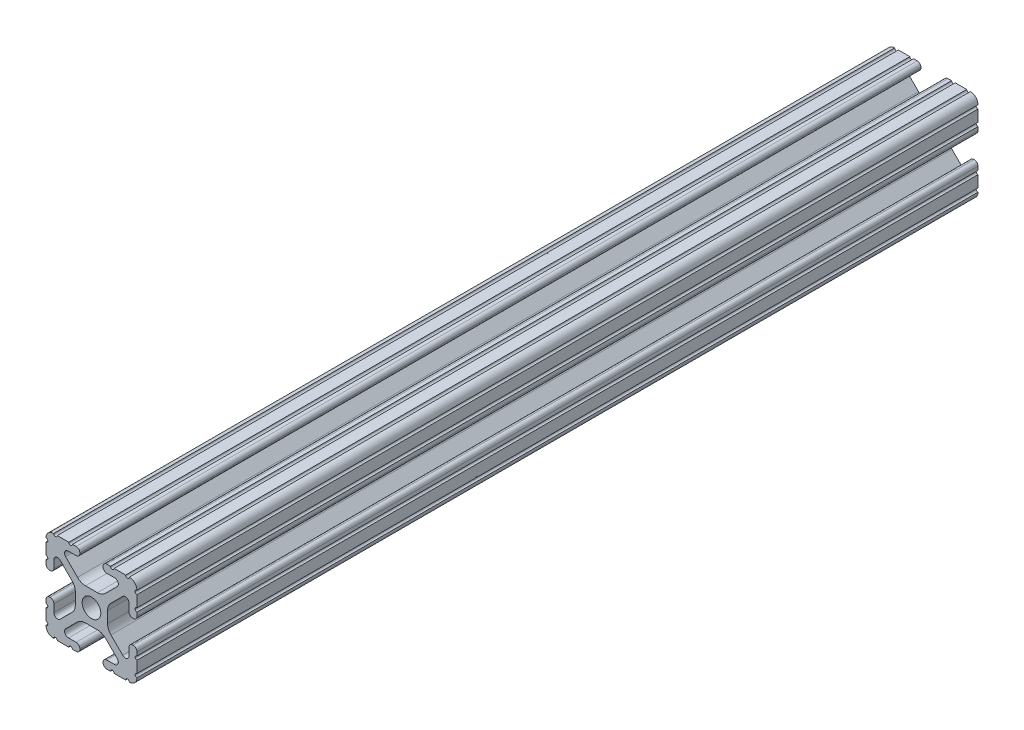
from build123d import *

# Parameters (mm, degrees)
SKETCH1_R           = 2.6035
BOSS_EXTRUDE1_DEPTH = 117.475


with BuildPart() as part:
    # Sketch1 → Boss-Extrude1 (new body, symmetric)
    with BuildSketch(Plane.XY):
        with BuildLine():
            Line((-7.179650497, -8.645192506), (-3.952270251, -5.423690499))
            ThreePointArc((-3.952270251, -5.423690499), (-2.922936451, -4.736929036), (-1.709253557, -4.4958))
            Line((-1.709253557, -4.4958), (1.709253557, -4.4958))
            ThreePointArc((1.709253557, -4.4958), (2.922936451, -4.736929036), (3.952270251, -5.423690499))
            Line((3.952270251, -5.423690499), (7.179650497, -8.645192506))
            ThreePointArc((7.179650497, -8.645192506), (7.41473083, -9.822813117), (6.416408329, -10.4902))
            Line((6.416408329, -10.4902), (4.287512407, -10.4902))
            ThreePointArc((4.287512407, -10.4902), (3.54574862, -10.79744862), (3.2385, -11.539212407))
            Line((3.2385, -11.539212407), (3.2385, -11.650987593))
            ThreePointArc((3.2385, -11.650987593), (3.54574862, -12.39275138), (4.287512407, -12.7))
            Line((4.287512407, -12.7), (5.317126718, -12.7))
            ThreePointArc((5.317126718, -12.7), (5.825126718, -12.192), (6.333126718, -12.7))
            Line((6.333126718, -12.7), (9.550443118, -12.7))
            ThreePointArc((9.550443118, -12.7), (10.058366869, -12.192000006), (10.566443095, -12.699847501))
            ThreePointArc((10.566443095, -12.699847501), (12.082537762, -12.08250727), (12.699846982, -10.566399977))
            ThreePointArc((12.699846982, -10.566399977), (12.192000006, -10.058323491), (12.7, -9.5504))
            Line((12.7, -9.5504), (12.7, -6.3330836))
            ThreePointArc((12.7, -6.3330836), (12.192, -5.8250836), (12.7, -5.3170836))
            Line((12.7, -5.3170836), (12.7, -4.287469289))
            ThreePointArc((12.7, -4.287469289), (12.39275138, -3.545705502), (11.650987593, -3.238456882))
            Line((11.650987593, -3.238456882), (11.539212407, -3.238456882))
            ThreePointArc((11.539212407, -3.238456882), (10.79744862, -3.545705502), (10.4902, -4.287469289))
            Line((10.4902, -4.287469289), (10.4902, -6.402089023))
            ThreePointArc((10.4902, -6.402089023), (9.856505071, -7.351067942), (8.737131347, -7.129408934))
            Line((8.737131347, -7.129408934), (5.441005833, -3.840816462))
            ThreePointArc((5.441005833, -3.840816462), (4.750877967, -2.809883091), (4.5085, -1.593185507))
            Line((4.5085, -1.593185507), (4.5085, 1.593185507))
            ThreePointArc((4.5085, 1.593185507), (4.750877967, 2.809883091), (5.441005833, 3.840816462))
            Line((5.441005833, 3.840816462), (8.737131347, 7.129408934))
            ThreePointArc((8.737131347, 7.129408934), (9.856505071, 7.351067942), (10.4902, 6.402089023))
            Line((10.4902, 6.402089023), (10.4902, 4.287469289))
            ThreePointArc((10.4902, 4.287469289), (10.79744862, 3.545705502), (11.539212407, 3.238456882))
            Line((11.539212407, 3.238456882), (11.650987593, 3.238456882))
            ThreePointArc((11.650987593, 3.238456882), (12.39275138, 3.545705502), (12.7, 4.287469289))
            Line((12.7, 4.287469289), (12.7, 5.3170836))
            ThreePointArc((12.7, 5.3170836), (12.192, 5.8250836), (12.7, 6.3330836))
            Line((12.7, 6.3330836), (12.7, 9.5504))
            ThreePointArc((12.7, 9.5504), (12.192000006, 10.058323491), (12.699846982, 10.566399977))
            ThreePointArc((12.699846982, 10.566399977), (12.082537762, 12.08250727), (10.566443095, 12.699847501))
            ThreePointArc((10.566443095, 12.699847501), (10.058366869, 12.192000006), (9.550443118, 12.7))
            Line((9.550443118, 12.7), (6.333126718, 12.7))
            ThreePointArc((6.333126718, 12.7), (5.825126718, 12.192), (5.317126718, 12.7))
            Line((5.317126718, 12.7), (4.287512407, 12.7))
            ThreePointArc((4.287512407, 12.7), (3.54574862, 12.39275138), (3.2385, 11.650987593))
            Line((3.2385, 11.650987593), (3.2385, 11.539212407))
            ThreePointArc((3.2385, 11.539212407), (3.54574862, 10.79744862), (4.287512407, 10.4902))
            Line((4.287512407, 10.4902), (6.476788598, 10.4902))
            ThreePointArc((6.476788598, 10.4902), (7.432222385, 9.85140422), (7.207036008, 8.724370562))
            Line((7.207036008, 8.724370562), (3.898272566, 5.423169045))
            ThreePointArc((3.898272566, 5.423169045), (2.869120213, 4.736787962), (1.655778399, 4.4958))
            Line((1.655778399, 4.4958), (-1.655778399, 4.4958))
            ThreePointArc((-1.655778399, 4.4958), (-2.869120213, 4.736787962), (-3.898272566, 5.423169045))
            Line((-3.898272566, 5.423169045), (-7.207036008, 8.724370562))
            ThreePointArc((-7.207036008, 8.724370562), (-7.432222385, 9.85140422), (-6.476788598, 10.4902))
            Line((-6.476788598, 10.4902), (-4.287512407, 10.4902))
            ThreePointArc((-4.287512407, 10.4902), (-3.54574862, 10.79744862), (-3.2385, 11.539212407))
            Line((-3.2385, 11.539212407), (-3.2385, 11.650987593))
            ThreePointArc((-3.2385, 11.650987593), (-3.54574862, 12.39275138), (-4.287512407, 12.7))
            Line((-4.287512407, 12.7), (-5.317126718, 12.7))
            ThreePointArc((-5.317126718, 12.7), (-5.825126718, 12.192), (-6.333126718, 12.7))
            Line((-6.333126718, 12.7), (-9.550443118, 12.7))
            ThreePointArc((-9.550443118, 12.7), (-10.058366869, 12.192000006), (-10.566443095, 12.699847501))
            ThreePointArc((-10.566443095, 12.699847501), (-12.082537762, 12.08250727), (-12.699846982, 10.566399977))
            ThreePointArc((-12.699846982, 10.566399977), (-12.192000006, 10.058323491), (-12.7, 9.5504))
            Line((-12.7, 9.5504), (-12.7, 6.3330836))
            ThreePointArc((-12.7, 6.3330836), (-12.192, 5.8250836), (-12.7, 5.3170836))
            Line((-12.7, 5.3170836), (-12.7, 4.287469289))
            ThreePointArc((-12.7, 4.287469289), (-12.39275138, 3.545705502), (-11.650987593, 3.238456882))
            Line((-11.650987593, 3.238456882), (-11.539212407, 3.238456882))
            ThreePointArc((-11.539212407, 3.238456882), (-10.79744862, 3.545705502), (-10.4902, 4.287469289))
            Line((-10.4902, 4.287469289), (-10.4902, 6.402089023))
            ThreePointArc((-10.4902, 6.402089023), (-9.856505071, 7.351067942), (-8.737131347, 7.129408934))
            Line((-8.737131347, 7.129408934), (-5.441005833, 3.840816462))
            ThreePointArc((-5.441005833, 3.840816462), (-4.750877967, 2.809883091), (-4.5085, 1.593185507))
            Line((-4.5085, 1.593185507), (-4.5085, -1.593185507))
            ThreePointArc((-4.5085, -1.593185507), (-4.750877967, -2.809883091), (-5.441005833, -3.840816462))
            Line((-5.441005833, -3.840816462), (-8.737131347, -7.129408934))
            ThreePointArc((-8.737131347, -7.129408934), (-9.856505071, -7.351067942), (-10.4902, -6.402089023))
            Line((-10.4902, -6.402089023), (-10.4902, -4.287469289))
            ThreePointArc((-10.4902, -4.287469289), (-10.79744862, -3.545705502), (-11.539212407, -3.238456882))
            Line((-11.539212407, -3.238456882), (-11.650987593, -3.238456882))
            ThreePointArc((-11.650987593, -3.238456882), (-12.39275138, -3.545705502), (-12.7, -4.287469289))
            Line((-12.7, -4.287469289), (-12.7, -5.3170836))
            ThreePointArc((-12.7, -5.3170836), (-12.192, -5.8250836), (-12.7, -6.3330836))
            Line((-12.7, -6.3330836), (-12.7, -9.5504))
            ThreePointArc((-12.7, -9.5504), (-12.192000006, -10.058323491), (-12.699846982, -10.566399977))
            ThreePointArc((-12.699846982, -10.566399977), (-12.082537762, -12.08250727), (-10.566443095, -12.699847501))
            ThreePointArc((-10.566443095, -12.699847501), (-10.058366869, -12.192000006), (-9.550443118, -12.7))
            Line((-9.550443118, -12.7), (-6.333126718, -12.7))
            ThreePointArc((-6.333126718, -12.7), (-5.825126718, -12.192), (-5.317126718, -12.7))
            Line((-5.317126718, -12.7), (-4.287512407, -12.7))
            ThreePointArc((-4.287512407, -12.7), (-3.54574862, -12.39275138), (-3.2385, -11.650987593))
            Line((-3.2385, -11.650987593), (-3.2385, -11.539212407))
            ThreePointArc((-3.2385, -11.539212407), (-3.54574862, -10.79744862), (-4.287512407, -10.4902))
            Line((-4.287512407, -10.4902), (-6.416408329, -10.4902))
            ThreePointArc((-6.416408329, -10.4902), (-7.41473083, -9.822813117), (-7.179650497, -8.645192506))
        make_face()
        Circle(SKETCH1_R, mode=Mode.SUBTRACT)
    extrude(amount=BOSS_EXTRUDE1_DEPTH, both=True)


solid = part.part
